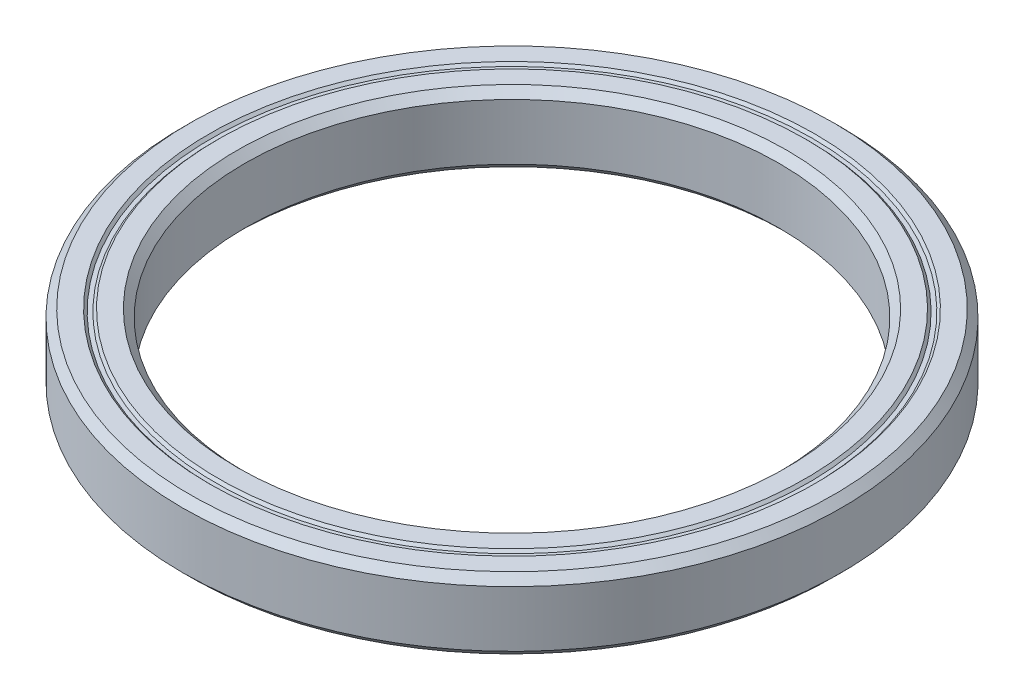
from build123d import *


with BuildPart() as part:
    # Sketch1 → Revolve1 (revolve)
    with BuildSketch(Plane.XY):
        Polygon((15, 1.5731), (15, -1.5731), (15.4269, -2), (16.49415, -2), (16.63645, -1.8577), (16.86355, -1.8577), (17.00585, -2), (18.0731, -2), (18.5, -1.5731), (18.5, 1.5731), (18.0731, 2), (17.00585, 2), (16.86355, 1.8577), (16.63645, 1.8577), (16.49415, 2), (15.4269, 2), align=None)
    revolve(axis=Axis((0, -1.349421972, 0), (0, 1, 0)))


solid = part.part
